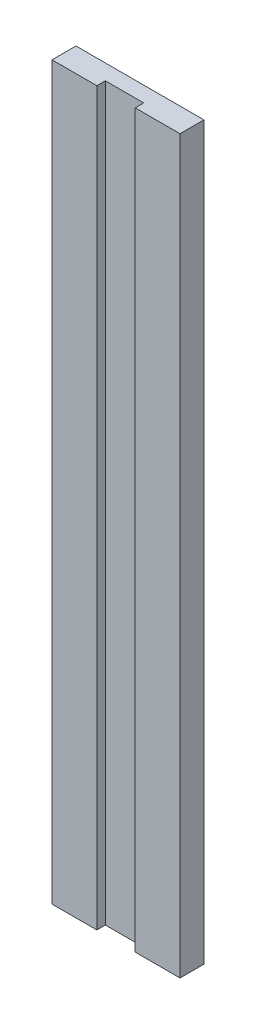
from build123d import *

# Parameters (mm, degrees)
SKETCH1_W           = 70
SKETCH1_H           = 400
BOSS_EXTRUDE1_DEPTH = 8.45
BOSS_EXTRUDE2_START = -8.45
SKETCH3_W           = 24.5
SKETCH3_H           = 400
BOSS_EXTRUDE2_DEPTH = 13.1


with BuildPart() as part:
    # Sketch1 → Boss-Extrude1 (new body)
    with BuildSketch(Plane.XY):
        Rectangle(SKETCH1_W, SKETCH1_H)
    extrude(amount=BOSS_EXTRUDE1_DEPTH)

    # Sketch3 → Boss-Extrude2 (add)
    with BuildSketch(Plane.XY.offset(8.45).offset(BOSS_EXTRUDE2_START)):
        with Locations((22.75, 0)):
            Rectangle(SKETCH3_W, SKETCH3_H)
        with Locations((-22.75, 0)):
            Rectangle(SKETCH3_W, SKETCH3_H)
    extrude(amount=BOSS_EXTRUDE2_DEPTH)


solid = part.part
